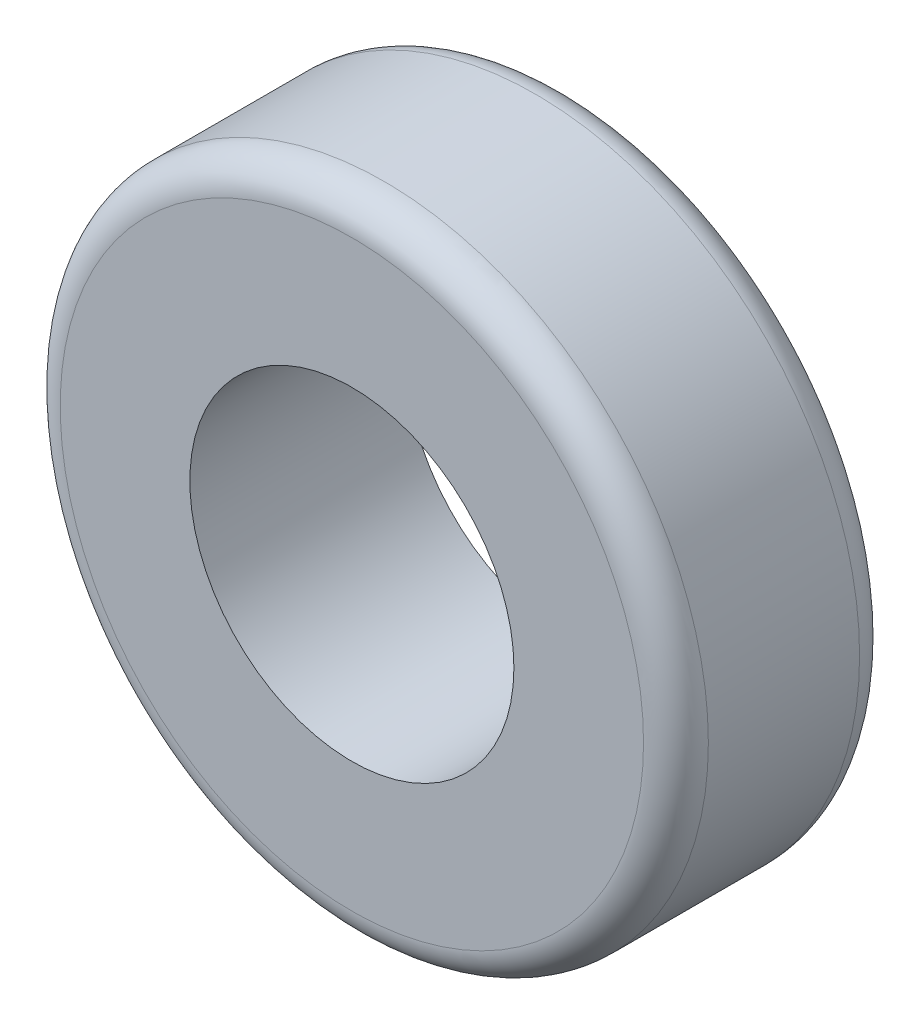
from build123d import *

# Parameters (mm, degrees)
SKETCH1_R           = 30
SKETCH1_R_2         = 15
BOSS_EXTRUDE1_DEPTH = 20
FILLET1_R           = 3


with BuildPart() as part:
    # Sketch1 → Boss-Extrude1 (new body)
    with BuildSketch(Plane.XY):
        Circle(SKETCH1_R)
        Circle(SKETCH1_R_2, mode=Mode.SUBTRACT)
    extrude(amount=BOSS_EXTRUDE1_DEPTH)

    # Fillet1
    fillet1_edges = [part.edges().sort_by_distance(p)[0] for p in [
        (-30, 0, 0),
        (-30, 0, 20),
    ]]
    fillet(fillet1_edges, radius=FILLET1_R)


solid = part.part
